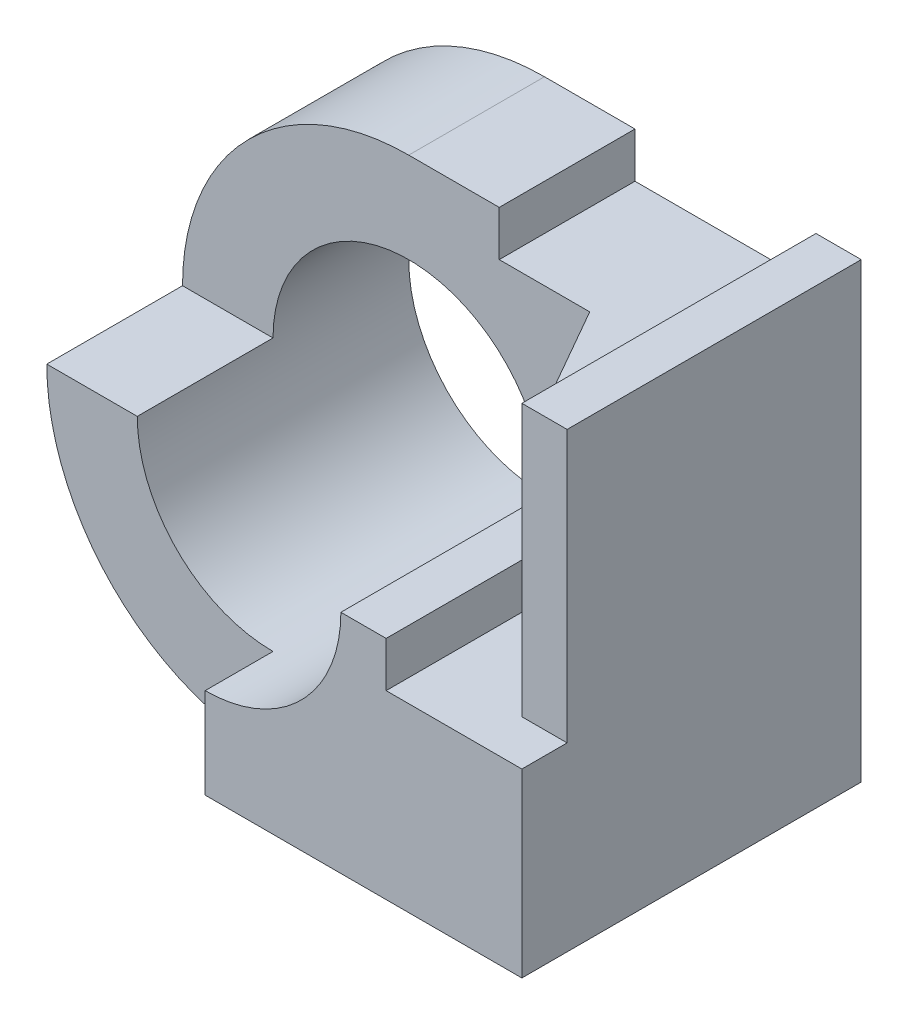
from build123d import *

# Parameters (mm, degrees)
SKETCH1_R           = 3
BOSS_EXTRUDE1_DEPTH = 7.5
SKETCH2_W           = 9
SKETCH2_H           = 5
CUT_EXTRUDE1_DEPTH  = 4.5
SKETCH3_W           = 5
SKETCH3_H           = 5
CUT_EXTRUDE2_DEPTH  = 1.5
CUT_EXTRUDE3_DEPTH  = 6


with BuildPart() as part:
    # Sketch1 → Boss-Extrude1 (new body)
    with BuildSketch(Plane.XY):
        with BuildLine():
            Line((-1.5, 5), (-3.5, 5))
            ThreePointArc((-3.5, 5), (-8.5, 0), (-3.5, -5))
            Line((-3.5, -5), (3.5, -5))
            Line((3.5, -5), (3.5, 5))
            Line((3.5, 5), (2.5, 5))
            Line((2.5, 5), (2.5, 4))
            Line((2.5, 4), (-1.5, 4))
            Line((-1.5, 4), (-1.5, 5))
        make_face()
        with Locations((-3.5, 0)):
            Circle(SKETCH1_R, mode=Mode.SUBTRACT)
    extrude(amount=BOSS_EXTRUDE1_DEPTH)

    # Sketch2 → Cut-Extrude1 (cut)
    with BuildSketch(Plane.XY.offset(7.5)):
        with Locations((-4, 2.5)):
            Rectangle(SKETCH2_W, SKETCH2_H)
    extrude(amount=-CUT_EXTRUDE1_DEPTH, mode=Mode.SUBTRACT)

    # Sketch3 → Cut-Extrude2 (cut)
    with BuildSketch(Plane.XY.offset(7.5)):
        with Locations((-6, -2.5)):
            Rectangle(SKETCH3_W, SKETCH3_H)
    extrude(amount=-CUT_EXTRUDE2_DEPTH, mode=Mode.SUBTRACT)

    # Sketch4 → Cut-Extrude3 (cut)
    with BuildSketch(Plane(origin=(0, 5, 0), x_dir=(1, 0, 0), z_dir=(0, 1, 0))):
        Polygon((3.5, -6.5), (2.5, -6.5), (0.5, -3), (0.5, -7.5), (3.5, -7.5), align=None)
    extrude(amount=-CUT_EXTRUDE3_DEPTH, mode=Mode.SUBTRACT)


solid = part.part
